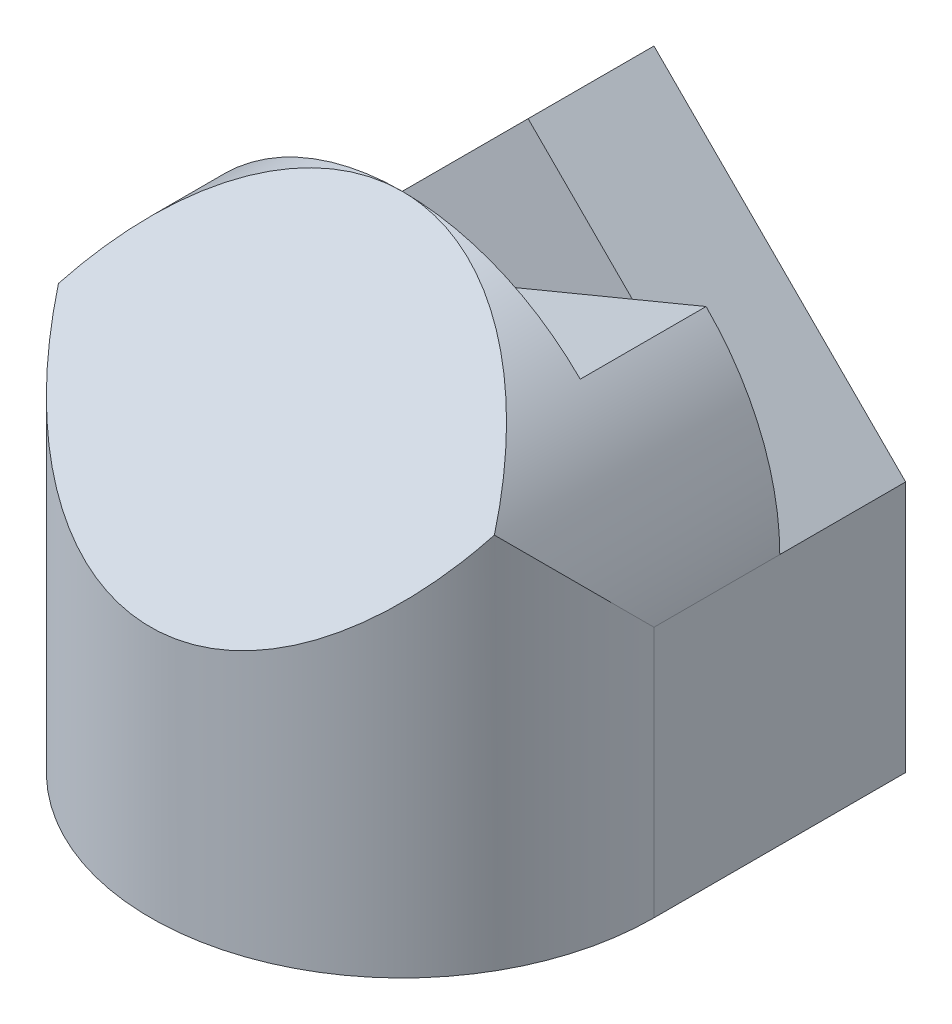
from build123d import *

# Parameters (mm, degrees)
SKETCH1_W           = 40
SKETCH1_H           = 20
BOSS_EXTRUDE1_DEPTH = 40
CUT_EXTRUDE1_DEPTH  = 40
CUT_EXTRUDE2_DEPTH  = 40
CUT_EXTRUDE3_DEPTH  = 10
CUT_EXTRUDE4_DEPTH  = 10
BOSS_EXTRUDE2_DEPTH = 10


with BuildPart() as part:
    # Sketch1 → Boss-Extrude1 (new body)
    with BuildSketch(Plane.XY):
        with BuildLine():
            Line((0, 20), (40, 20))
            ThreePointArc((40, 20), (20, 40), (0, 20))
        make_face()
        with Locations((20, 10)):
            Rectangle(SKETCH1_W, SKETCH1_H)
    extrude(amount=BOSS_EXTRUDE1_DEPTH)

    # Sketch2 → Cut-Extrude1 (cut)
    with BuildSketch(Plane(origin=(0, 0, 0), x_dir=(1, 0, 0), z_dir=(0, 1, 0))):
        with BuildLine():
            Line((0, -20), (0, -40))
            Line((0, -40), (20, -40))
            ThreePointArc((20, -40), (5.857864, -34.142136), (0, -20))
        make_face()
        with BuildLine():
            ThreePointArc((40, -20), (34.142136, -34.142136), (20, -40))
            Line((20, -40), (40, -40))
            Line((40, -40), (40, -20))
        make_face()
    extrude(amount=CUT_EXTRUDE1_DEPTH, mode=Mode.SUBTRACT)

    # Sketch3 → Cut-Extrude2 (cut)
    with BuildSketch(Plane(origin=(0, 0, 0), x_dir=(0, 0, -1), z_dir=(1, 0, 0))):
        Polygon((-40, 20), (-20, 40), (-40, 40), align=None)
    extrude(amount=CUT_EXTRUDE2_DEPTH, mode=Mode.SUBTRACT)

    # Sketch4 → Cut-Extrude3 (cut)
    with BuildSketch(Plane(origin=(0, 0, 0), x_dir=(-1, 0, 0), z_dir=(0, 0, -1))):
        with BuildLine():
            Line((-40, 20), (-20, 40))
            ThreePointArc((-20, 40), (-34.142136, 34.142136), (-40, 20))
        make_face()
        with BuildLine():
            ThreePointArc((0, 20), (-5.857864, 34.142136), (-20, 40))
            Line((-20, 40), (0, 20))
        make_face()
    extrude(amount=-CUT_EXTRUDE3_DEPTH, mode=Mode.SUBTRACT)

    # Sketch5 → Cut-Extrude4 (cut)
    with BuildSketch(Plane.XY.offset(10)):
        Polygon((40, 20), (40, 40), (0, 20), align=None)
        with BuildLine():
            ThreePointArc((32, 36), (11.055728, 37.888544), (0, 20))
            Line((0, 20), (32, 36))
        make_face()
    extrude(amount=CUT_EXTRUDE4_DEPTH, mode=Mode.SUBTRACT)

    # Sketch7 → Boss-Extrude2 (add)
    with BuildSketch(Plane(origin=(0, 0, 20), x_dir=(-1, 0, 0), z_dir=(0, 0, -1))):
        with BuildLine():
            Line((0, 20), (-34.142136, 34.142136))
            ThreePointArc((-34.142136, 34.142136), (-38.477591, 27.653669), (-40, 20))
            Line((-40, 20), (0, 20))
        make_face()
    extrude(amount=BOSS_EXTRUDE2_DEPTH)


solid = part.part
